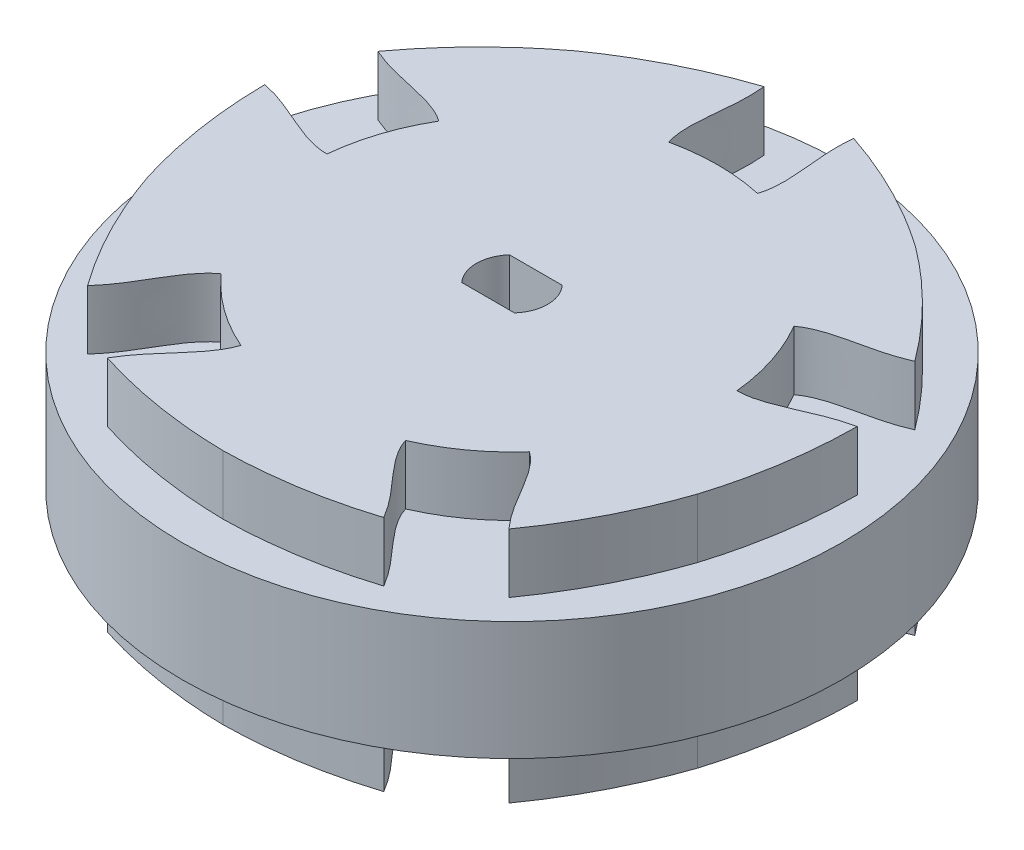
from build123d import *

# Parameters (mm, degrees)
SKETCH1_R           = 15.617178034
BOSS_EXTRUDE2_DEPTH = 18
BOSS_EXTRUDE3_START = -4.5
SKETCH3_R           = 25
BOSS_EXTRUDE3_DEPTH = 9
CUT_EXTRUDE1_DEPTH  = 18


with BuildPart() as part:
    # Sketch1 → Boss-Extrude2 (new body)
    with BuildSketch(Plane(origin=(0, 0, 0), x_dir=(1, 0, 0), z_dir=(0, 1, 0))):
        with BuildLine():
            add(Edge.make_bspline(
                [(10.482017964, -20.206109564), (9.100784648, -17.807532927), (6.885004904, -16.33342402), (6.241938333, -14.31553197)],
                knots=[0.184963851, 0.184963851, 0.184963851, 0.184963851, 1, 1, 1, 1], degree=3))
            ThreePointArc((6.241938333, -14.31553197), (0, -15.617178034), (-6.241938333, -14.31553197))
            add(Edge.make_bspline(
                [(-10.482017964, -20.206109564), (-9.100784648, -17.807532927), (-6.885004904, -16.33342402), (-6.241938333, -14.31553197)],
                knots=[0.184963851, 0.184963851, 0.184963851, 0.184963851, 1, 1, 1, 1], degree=3))
            add(Edge.make_bspline(
                [(-10.482017964, -20.206109564), (-5.360025811, -21.82690053), (0, -21.905896537)],
                knots=[0, 0, 0, 1, 1, 1], degree=2))
            add(Edge.make_bspline(
                [(10.482017964, -20.206109564), (5.360025811, -21.82690053), (0, -21.905896537)],
                knots=[0, 0, 0, 1, 1, 1], degree=2))
        make_face()
        Circle(SKETCH1_R)
        with BuildLine():
            add(Edge.make_bspline(
                [(-15.978030483, -16.213022734), (-14.123673111, -14.158190845), (-13.406425826, -11.595334377), (-11.686014942, -10.360178788)],
                knots=[0.184963851, 0.184963851, 0.184963851, 0.184963851, 1, 1, 1, 1], degree=3))
            ThreePointArc((-11.686014942, -10.360178788), (-14.852818935, -4.825973417), (-15.543744987, 1.512693463))
            add(Edge.make_bspline(
                [(-22.456273856, 3.724960243), (-19.748267348, 3.152530241), (-17.661592869, 1.50072318), (-15.543744987, 1.512693463)],
                knots=[0.184963851, 0.184963851, 0.184963851, 0.184963851, 1, 1, 1, 1], degree=3))
            add(Edge.make_bspline(
                [(-22.456273856, 3.724960243), (-22.414955045, -1.647195723), (-20.833745647, -6.769294307)],
                knots=[0, 0, 0, 1, 1, 1], degree=2))
            add(Edge.make_bspline(
                [(-15.978030483, -16.213022734), (-19.102276913, -11.842570674), (-20.833745647, -6.769294307)],
                knots=[0, 0, 0, 1, 1, 1], degree=2))
        make_face()
        with BuildLine():
            ThreePointArc((-13.46429276, 7.91258935), (-9.179546931, 12.634562434), (-3.364624382, 15.250427945))
            add(Edge.make_bspline(
                [(-3.39672254, 22.5082616), (-3.104315792, 19.755903766), (-4.030459785, 17.260921953), (-3.364624382, 15.250427945)],
                knots=[0.184963851, 0.184963851, 0.184963851, 0.184963851, 1, 1, 1, 1], degree=3))
            add(Edge.make_bspline(
                [(-3.39672254, 22.5082616), (-8.493178263, 20.808877587), (-12.875962923, 17.722242576)],
                knots=[0, 0, 0, 1, 1, 1], degree=2))
            add(Edge.make_bspline(
                [(-20.356983876, 10.185910454), (-17.165882206, 14.507789339), (-12.875962923, 17.722242576)],
                knots=[0, 0, 0, 1, 1, 1], degree=2))
            add(Edge.make_bspline(
                [(-20.356983876, 10.185910454), (-17.829694677, 9.057289765), (-15.170631732, 9.167113264), (-13.46429276, 7.91258935)],
                knots=[0.184963851, 0.184963851, 0.184963851, 0.184963851, 1, 1, 1, 1], degree=3))
        make_face()
        with BuildLine():
            ThreePointArc((3.364624382, 15.250427945), (9.179546931, 12.634562434), (13.46429276, 7.91258935))
            add(Edge.make_bspline(
                [(20.356983876, 10.185910454), (17.829694677, 9.057289765), (15.170631732, 9.167113264), (13.46429276, 7.91258935)],
                knots=[0.184963851, 0.184963851, 0.184963851, 0.184963851, 1, 1, 1, 1], degree=3))
            add(Edge.make_bspline(
                [(20.356983876, 10.185910454), (17.165882206, 14.507789339), (12.875962923, 17.722242576)],
                knots=[0, 0, 0, 1, 1, 1], degree=2))
            add(Edge.make_bspline(
                [(3.39672254, 22.5082616), (8.493178263, 20.808877587), (12.875962923, 17.722242576)],
                knots=[0, 0, 0, 1, 1, 1], degree=2))
            add(Edge.make_bspline(
                [(3.39672254, 22.5082616), (3.104315792, 19.755903766), (4.030459785, 17.260921953), (3.364624382, 15.250427945)],
                knots=[0.184963851, 0.184963851, 0.184963851, 0.184963851, 1, 1, 1, 1], degree=3))
        make_face()
        with BuildLine():
            ThreePointArc((15.543744987, 1.512693463), (15.598808969, 0.757237401), (15.617178034, 0))
            ThreePointArc((15.617178034, 0), (14.601349691, -5.540472628), (11.686014942, -10.360178788))
            add(Edge.make_bspline(
                [(15.978030483, -16.213022734), (14.123673111, -14.158190845), (13.406425826, -11.595334377), (11.686014942, -10.360178788)],
                knots=[0.184963851, 0.184963851, 0.184963851, 0.184963851, 1, 1, 1, 1], degree=3))
            add(Edge.make_bspline(
                [(15.978030483, -16.213022734), (19.102276913, -11.842570674), (20.833745647, -6.769294307)],
                knots=[0, 0, 0, 1, 1, 1], degree=2))
            add(Edge.make_bspline(
                [(22.456273856, 3.724960243), (22.414955045, -1.647195723), (20.833745647, -6.769294307)],
                knots=[0, 0, 0, 1, 1, 1], degree=2))
            add(Edge.make_bspline(
                [(22.456273856, 3.724960243), (19.748267348, 3.152530241), (17.661592869, 1.50072318), (15.543744987, 1.512693463)],
                knots=[0.184963851, 0.184963851, 0.184963851, 0.184963851, 1, 1, 1, 1], degree=3))
        make_face()
    extrude(amount=BOSS_EXTRUDE2_DEPTH)

    # Sketch3 → Boss-Extrude3 (add)
    with BuildSketch(Plane(origin=(0, 18, 0), x_dir=(1, 0, 0), z_dir=(0, 1, 0)).offset(BOSS_EXTRUDE3_START)):
        Circle(SKETCH3_R)
    extrude(amount=-BOSS_EXTRUDE3_DEPTH)

    # Sketch4 → Cut-Extrude1 (cut)
    with BuildSketch(Plane(origin=(0, 18, 0), x_dir=(1, 0, 0), z_dir=(0, 1, 0))):
        with BuildLine():
            Line((-2, 1.813835715), (2, 1.813835715))
            ThreePointArc((2, 1.813835715), (2.7, 0), (2, -1.813835715))
            Line((2, -1.813835715), (-2, -1.813835715))
            ThreePointArc((-2, -1.813835715), (-2.7, 0), (-2, 1.813835715))
        make_face()
    extrude(amount=-CUT_EXTRUDE1_DEPTH, mode=Mode.SUBTRACT)


solid = part.part
